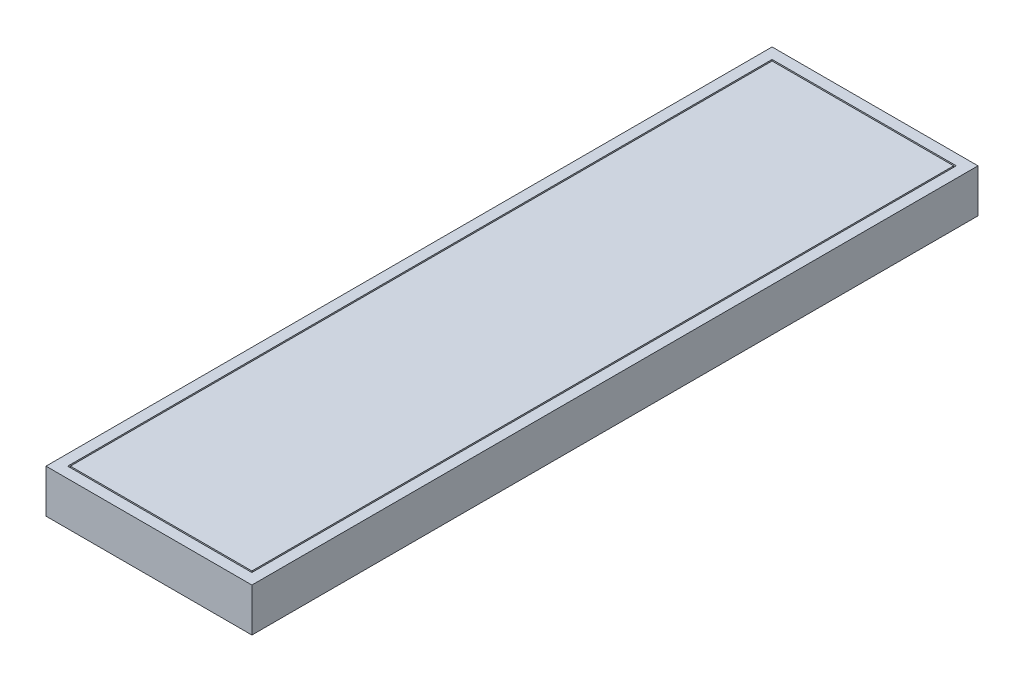
from build123d import *

# Parameters (mm, degrees)
SKETCH1_W           = 380
SKETCH1_H           = 1340
BOSS_EXTRUDE1_DEPTH = 80
SKETCH2_W           = 340
SKETCH2_H           = 1300
CUT_EXTRUDE1_DEPTH  = 11
SKETCH3_W           = 335
SKETCH3_H           = 1295
BOSS_EXTRUDE2_DEPTH = 11


with BuildPart() as part:
    # Sketch1 → Boss-Extrude1 (new body)
    with BuildSketch(Plane.XZ.offset(60)):
        with Locations((0, 670)):
            Rectangle(SKETCH1_W, SKETCH1_H)
    extrude(amount=-BOSS_EXTRUDE1_DEPTH)

    # Sketch2 → Cut-Extrude1 (cut)
    with BuildSketch(Plane(origin=(0, 20, 0), x_dir=(-1, 0, 0), z_dir=(0, 1, 0))):
        with Locations((0, 670)):
            Rectangle(SKETCH2_W, SKETCH2_H)
    extrude(amount=-CUT_EXTRUDE1_DEPTH, mode=Mode.SUBTRACT)

    # Sketch3 → Boss-Extrude2 (add)
    with BuildSketch(Plane(origin=(0, 9, 0), x_dir=(-1, 0, 0), z_dir=(0, 1, 0))):
        with Locations((0, 670)):
            Rectangle(SKETCH3_W, SKETCH3_H)
    extrude(amount=BOSS_EXTRUDE2_DEPTH)


solid = part.part
